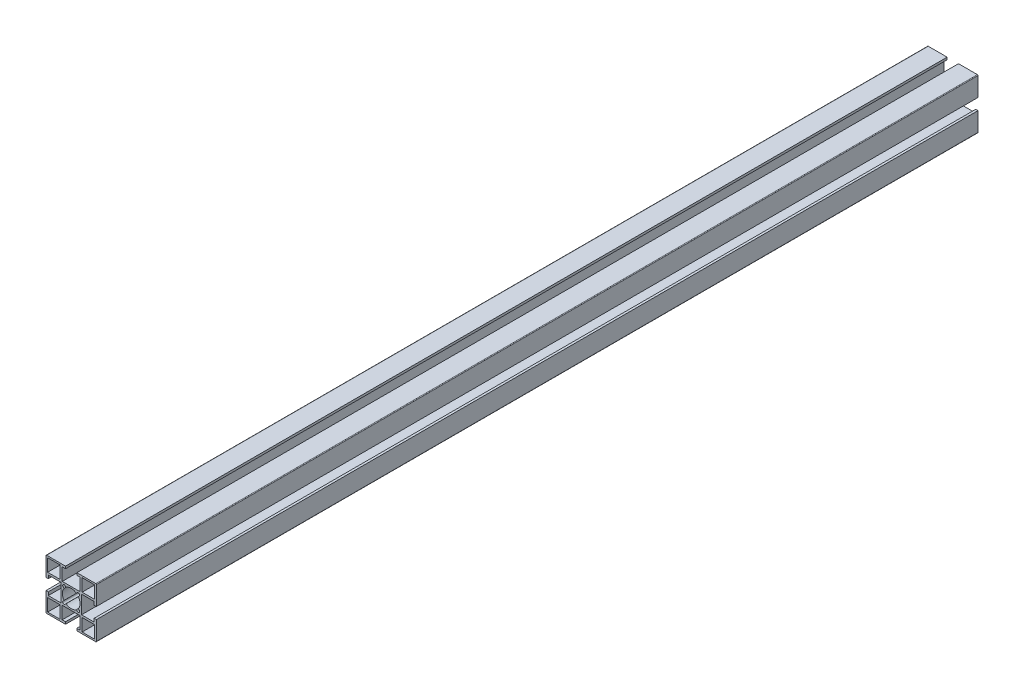
from build123d import *

# Parameters (mm, degrees)
SKETCH1_W                 = 10
SKETCH1_H                 = 10
F_40_X_40A_X_R0_5_1_DEPTH = 700


with BuildPart() as part:
    # Sketch1 → 铝型材 40 X 40A X R0.5(1) (new body)
    with BuildSketch(Plane.YX):
        with BuildLine():
            Line((-19.5, 20), (-4.5, 20))
            Line((-4.5, 20), (-4.5, 18.2))
            Line((-4.5, 18.2), (-7.1, 18.2))
            Line((-7.1, 18.2), (-7.1, 8.2))
            Line((-7.1, 8.2), (7.1, 8.2))
            Line((7.1, 8.2), (7.1, 18.2))
            Line((7.1, 18.2), (4.5, 18.2))
            Line((4.5, 18.2), (4.5, 20))
            Line((4.5, 20), (19.5, 20))
            ThreePointArc((19.5, 20), (19.853553391, 19.853553391), (20, 19.5))
            Line((20, 19.5), (20, 4.5))
            Line((20, 4.5), (18.2, 4.5))
            Line((18.2, 4.5), (18.2, 7.1))
            Line((18.2, 7.1), (8.2, 7.1))
            Line((8.2, 7.1), (8.2, -7.1))
            Line((8.2, -7.1), (18.2, -7.1))
            Line((18.2, -7.1), (18.2, -4.5))
            Line((18.2, -4.5), (20, -4.5))
            Line((20, -4.5), (20, -19.5))
            ThreePointArc((20, -19.5), (19.853553391, -19.853553391), (19.5, -20))
            Line((19.5, -20), (4.5, -20))
            Line((4.5, -20), (4.5, -18.2))
            Line((4.5, -18.2), (7.1, -18.2))
            Line((7.1, -18.2), (7.1, -8.2))
            Line((7.1, -8.2), (-7.1, -8.2))
            Line((-7.1, -8.2), (-7.1, -18.2))
            Line((-7.1, -18.2), (-4.5, -18.2))
            Line((-4.5, -18.2), (-4.5, -20))
            Line((-4.5, -20), (-19.5, -20))
            ThreePointArc((-19.5, -20), (-19.853553391, -19.853553391), (-20, -19.5))
            Line((-20, -19.5), (-20, -4.5))
            Line((-20, -4.5), (-18.2, -4.5))
            Line((-18.2, -4.5), (-18.2, -7.1))
            Line((-18.2, -7.1), (-8.2, -7.1))
            Line((-8.2, -7.1), (-8.2, 7.1))
            Line((-8.2, 7.1), (-18.2, 7.1))
            Line((-18.2, 7.1), (-18.2, 4.5))
            Line((-18.2, 4.5), (-20, 4.5))
            Line((-20, 4.5), (-20, 19.5))
            ThreePointArc((-20, 19.5), (-19.853553391, 19.853553391), (-19.5, 20))
        make_face()
        with BuildLine():
            Line((-4.87903679, 6.434671709), (-4.110433762, 5.66606868))
            ThreePointArc((-4.110433762, 5.66606868), (0, 7), (4.110433762, 5.66606868))
            Line((4.110433762, 5.66606868), (4.87903679, 6.434671709))
            ThreePointArc((4.87903679, 6.434671709), (6.434671709, 6.434671709), (6.434671709, 4.87903679))
            Line((6.434671709, 4.87903679), (5.66606868, 4.110433762))
            ThreePointArc((5.66606868, 4.110433762), (7, 0), (5.66606868, -4.110433762))
            Line((5.66606868, -4.110433762), (6.434671709, -4.87903679))
            ThreePointArc((6.434671709, -4.87903679), (6.434671709, -6.434671709), (4.87903679, -6.434671709))
            Line((4.87903679, -6.434671709), (4.110433762, -5.66606868))
            ThreePointArc((4.110433762, -5.66606868), (0, -7), (-4.110433762, -5.66606868))
            Line((-4.110433762, -5.66606868), (-4.87903679, -6.434671709))
            ThreePointArc((-4.87903679, -6.434671709), (-6.434671709, -6.434671709), (-6.434671709, -4.87903679))
            Line((-6.434671709, -4.87903679), (-5.66606868, -4.110433762))
            ThreePointArc((-5.66606868, -4.110433762), (-7, 0), (-5.66606868, 4.110433762))
            Line((-5.66606868, 4.110433762), (-6.434671709, 4.87903679))
            ThreePointArc((-6.434671709, 4.87903679), (-6.434671709, 6.434671709), (-4.87903679, 6.434671709))
        make_face(mode=Mode.SUBTRACT)
        with Locations((-13.7, 13.7)):
            Rectangle(SKETCH1_W, SKETCH1_H, mode=Mode.SUBTRACT)
        with Locations((13.7, 13.7)):
            Rectangle(SKETCH1_W, SKETCH1_H, mode=Mode.SUBTRACT)
        with Locations((13.7, -13.7)):
            Rectangle(SKETCH1_W, SKETCH1_H, mode=Mode.SUBTRACT)
        with Locations((-13.7, -13.7)):
            Rectangle(SKETCH1_W, SKETCH1_H, mode=Mode.SUBTRACT)
    extrude(amount=F_40_X_40A_X_R0_5_1_DEPTH)


solid = part.part
